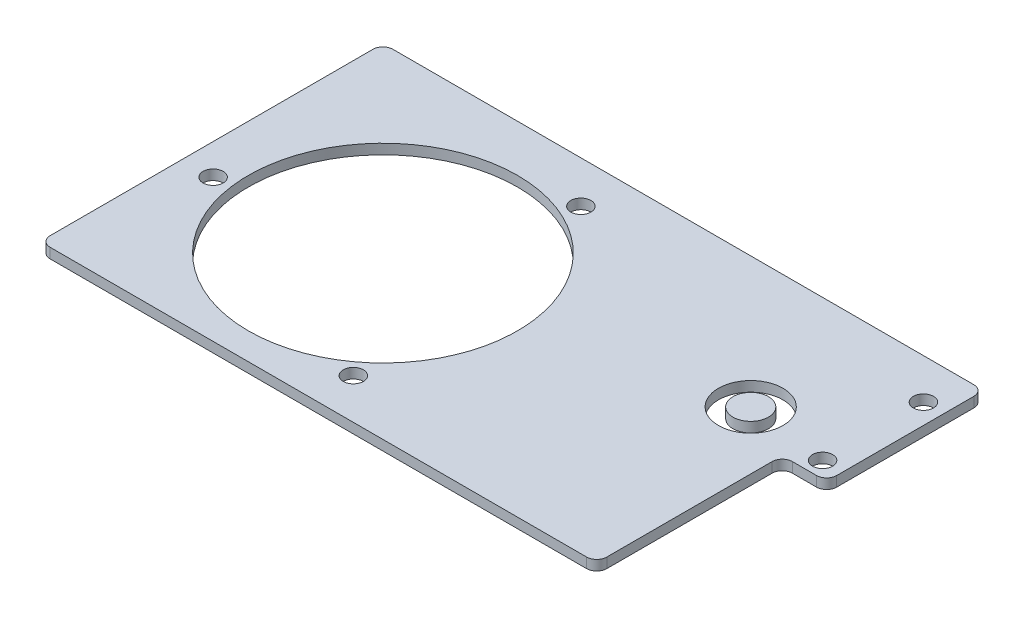
from build123d import *

# Parameters (mm, degrees)
SKETCH1_R           = 84.7725
SKETCH1_R_2         = 6.35
BOSS_EXTRUDE1_DEPTH = 6.35
SKETCH4_R           = 20.32
SKETCH4_R_2         = 11.176
CUT_EXTRUDE1_DEPTH  = 9.652


with BuildPart() as part:
    # Sketch1 → Boss-Extrude1 (new body)
    with BuildSketch(Plane(origin=(0, 0, 0), x_dir=(1, 0, 0), z_dir=(0, 1, 0))):
        with BuildLine():
            Line((257.81, 114.3), (-107.95, 114.3))
            ThreePointArc((-107.95, 114.3), (-112.440128061, 112.440128061), (-114.3, 107.95))
            Line((-114.3, 107.95), (-114.3, -95.25))
            ThreePointArc((-114.3, -95.25), (-112.440128061, -99.740128061), (-107.95, -101.6))
            Line((-107.95, -101.6), (229.87, -101.6))
            ThreePointArc((229.87, -101.6), (234.360128061, -99.740128061), (236.22, -95.25))
            Line((236.22, -95.25), (236.22, 8.89))
            ThreePointArc((236.22, 8.89), (238.079871939, 13.380128061), (242.57, 15.24))
            Line((242.57, 15.24), (257.81, 15.24))
            ThreePointArc((257.81, 15.24), (262.300128061, 17.099871939), (264.16, 21.59))
            Line((264.16, 21.59), (264.16, 107.95))
            ThreePointArc((264.16, 107.95), (262.300128061, 112.440128061), (257.81, 114.3))
        make_face()
        Circle(SKETCH1_R, mode=Mode.SUBTRACT)
        with Locations((-94.868167092, -12.066247058)):
            Circle(SKETCH1_R_2, mode=Mode.SUBTRACT)
        with Locations((36.791640664, 87.857485038)):
            Circle(SKETCH1_R_2, mode=Mode.SUBTRACT)
        with Locations((57.498227222, -76.125119184)):
            Circle(SKETCH1_R_2, mode=Mode.SUBTRACT)
        with Locations((251.46, 88.9)):
            Circle(SKETCH1_R_2, mode=Mode.SUBTRACT)
        with Locations((251.46, 25.4)):
            Circle(SKETCH1_R_2, mode=Mode.SUBTRACT)
    extrude(amount=BOSS_EXTRUDE1_DEPTH)

    # Sketch4 → Cut-Extrude1 (cut)
    with BuildSketch(Plane(origin=(0, 6.35, 0), x_dir=(1, 0, 0), z_dir=(0, 1, 0))):
        with Locations((199.663269189, 31.949583289)):
            Circle(SKETCH4_R)
        with Locations((199.663269189, 31.949583289)):
            Circle(SKETCH4_R_2, mode=Mode.SUBTRACT)
    extrude(amount=-CUT_EXTRUDE1_DEPTH, mode=Mode.SUBTRACT)


solid = part.part
